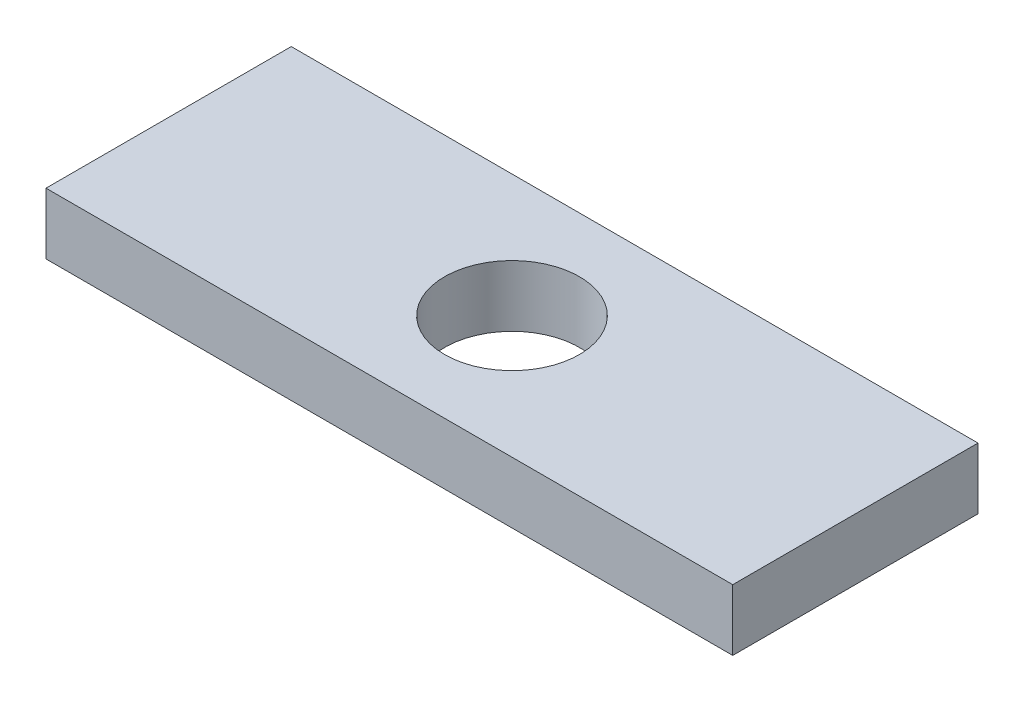
from build123d import *

# Parameters (mm, degrees)
SKETCH1_W           = 35.56
SKETCH1_H           = 12.7
SKETCH1_R           = 3.4925
BOSS_EXTRUDE1_DEPTH = 3.175


with BuildPart() as part:
    # Sketch1 → Boss-Extrude1 (new body)
    with BuildSketch(Plane(origin=(0, 0, 0), x_dir=(1, 0, 0), z_dir=(0, 1, 0))):
        Rectangle(SKETCH1_W, SKETCH1_H)
        Circle(SKETCH1_R, mode=Mode.SUBTRACT)
    extrude(amount=BOSS_EXTRUDE1_DEPTH)


solid = part.part
